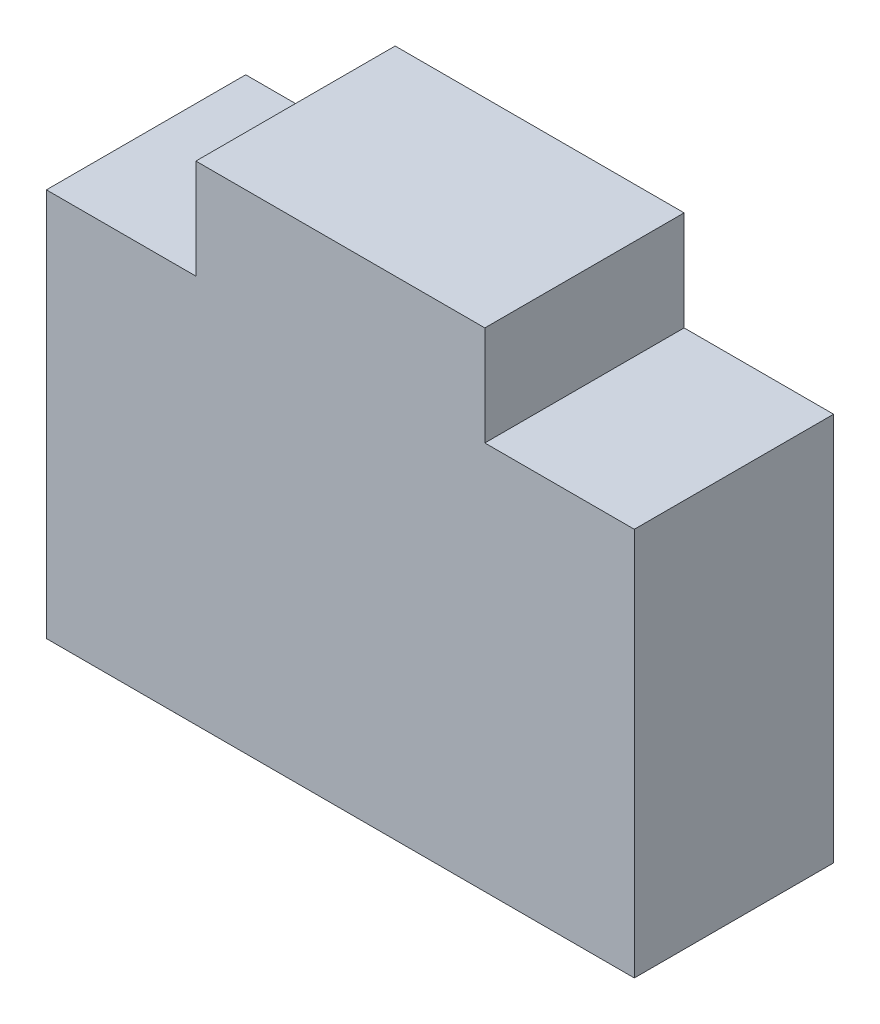
from build123d import *

# Parameters (mm, degrees)
BOSS_EXTRUDE1_DEPTH = 2


with BuildPart() as part:
    # Sketch1 → Boss-Extrude1 (new body)
    with BuildSketch(Plane.XY):
        Polygon((-1.45, 0), (1.45, 0), (1.45, -1), (2.95, -1), (2.95, -4.9), (-2.95, -4.9), (-2.95, -1), (-1.45, -1), align=None)
    extrude(amount=BOSS_EXTRUDE1_DEPTH)


solid = part.part
